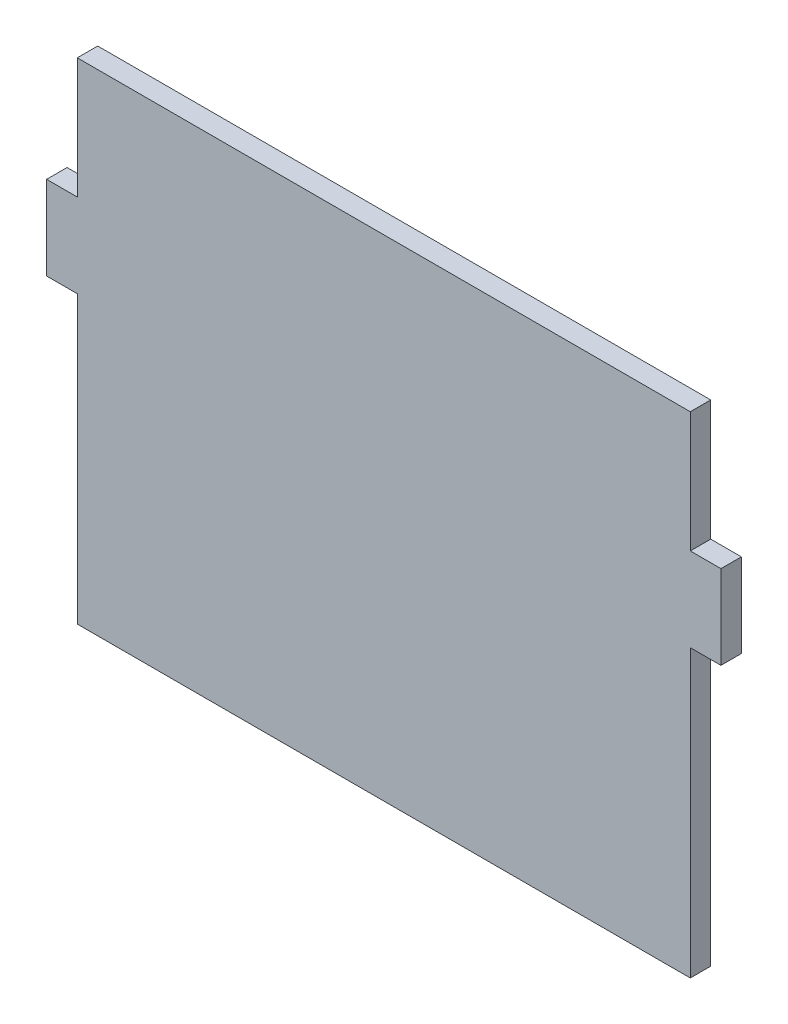
from build123d import *

# Parameters (mm, degrees)
Y_KSEKLIK_EKSTR_ZYON1_DEPTH = 10


with BuildPart() as part:
    # Çizim1 → Yükseklik-Ekstrüzyon1 (new body)
    with BuildSketch(Plane.XY):
        Polygon((-150, -120), (-150, 20), (-165, 20), (-165, 61), (-150, 61), (-150, 120), (150, 120), (150, 61), (165, 61), (165, 20), (150, 20), (150, -120), align=None)
    extrude(amount=Y_KSEKLIK_EKSTR_ZYON1_DEPTH)


solid = part.part
